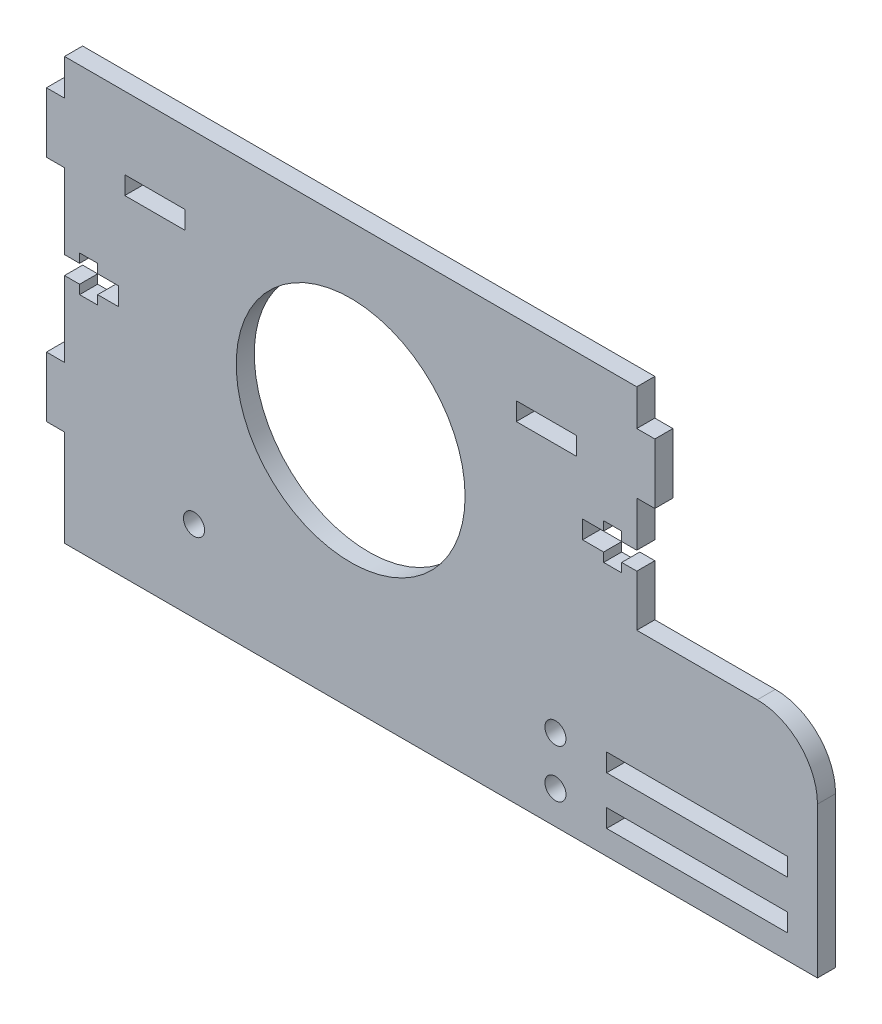
from build123d import *

# Parameters (mm, degrees)
SKETCH1_R           = 19
SKETCH1_R_2         = 1.75
SKETCH1_W           = 30
SKETCH1_H           = 3
SKETCH1_W_2         = 10
BOSS_EXTRUDE3_DEPTH = 3


with BuildPart() as part:
    # Sketch1 → Boss-Extrude3 (new body)
    with BuildSketch(Plane.XY):
        with BuildLine():
            Line((-47.5, 30), (47.5, 30))
            Line((47.5, 30), (47.5, 24))
            Line((47.5, 24), (50.5, 24))
            Line((50.5, 24), (50.5, 14))
            Line((50.5, 14), (47.5, 14))
            Line((47.5, 14), (47.5, 6.5))
            Line((47.5, 6.5), (45, 6.5))
            Line((45, 6.5), (45, 8))
            Line((45, 8), (42, 8))
            Line((42, 8), (42, 6.5))
            Line((42, 6.5), (38.5, 6.5))
            Line((38.5, 6.5), (38.5, 3.5))
            Line((38.5, 3.5), (42, 3.5))
            Line((42, 3.5), (42, 2))
            Line((42, 2), (45, 2))
            Line((45, 2), (45, 3.5))
            Line((45, 3.5), (47.5, 3.5))
            Line((47.5, 3.5), (47.5, -5))
            Line((47.5, -5), (67.5, -5))
            ThreePointArc((67.5, -5), (74.571067812, -7.928932188), (77.5, -15))
            Line((77.5, -15), (77.5, -30))
            Line((77.5, -30), (77.5, -40))
            Line((77.5, -40), (-47.5, -40))
            Line((-47.5, -40), (-47.5, -30))
            Line((-47.5, -30), (-47.5, -24))
            Line((-47.5, -24), (-50.5, -24))
            Line((-50.5, -24), (-50.5, -14))
            Line((-50.5, -14), (-47.5, -14))
            Line((-47.5, -14), (-47.5, -1.5))
            Line((-47.5, -1.5), (-45, -1.5))
            Line((-45, -1.5), (-45, -3))
            Line((-45, -3), (-42, -3))
            Line((-42, -3), (-42, -1.5))
            Line((-42, -1.5), (-38.5, -1.5))
            Line((-38.5, -1.5), (-38.5, 1.5))
            Line((-38.5, 1.5), (-42, 1.5))
            Line((-42, 1.5), (-42, 3))
            Line((-42, 3), (-45, 3))
            Line((-45, 3), (-45, 1.5))
            Line((-45, 1.5), (-47.5, 1.5))
            Line((-47.5, 1.5), (-47.5, 14))
            Line((-47.5, 14), (-50.5, 14))
            Line((-50.5, 14), (-50.5, 24))
            Line((-50.5, 24), (-47.5, 24))
            Line((-47.5, 24), (-47.5, 30))
        make_face()
        Circle(SKETCH1_R, mode=Mode.SUBTRACT)
        with Locations((-26, -26.5)):
            Circle(SKETCH1_R_2, mode=Mode.SUBTRACT)
        with Locations((34, -26.5)):
            Circle(SKETCH1_R_2, mode=Mode.SUBTRACT)
        with Locations((34, -34.5)):
            Circle(SKETCH1_R_2, mode=Mode.SUBTRACT)
        with Locations((57.5, -26.5)):
            Rectangle(SKETCH1_W, SKETCH1_H, mode=Mode.SUBTRACT)
        with Locations((-32.5, 16.5)):
            Rectangle(SKETCH1_W_2, SKETCH1_H, mode=Mode.SUBTRACT)
        with Locations((32.5, 16.5)):
            Rectangle(SKETCH1_W_2, SKETCH1_H, mode=Mode.SUBTRACT)
        with Locations((57.5, -34.5)):
            Rectangle(SKETCH1_W, SKETCH1_H, mode=Mode.SUBTRACT)
    extrude(amount=BOSS_EXTRUDE3_DEPTH)


solid = part.part
